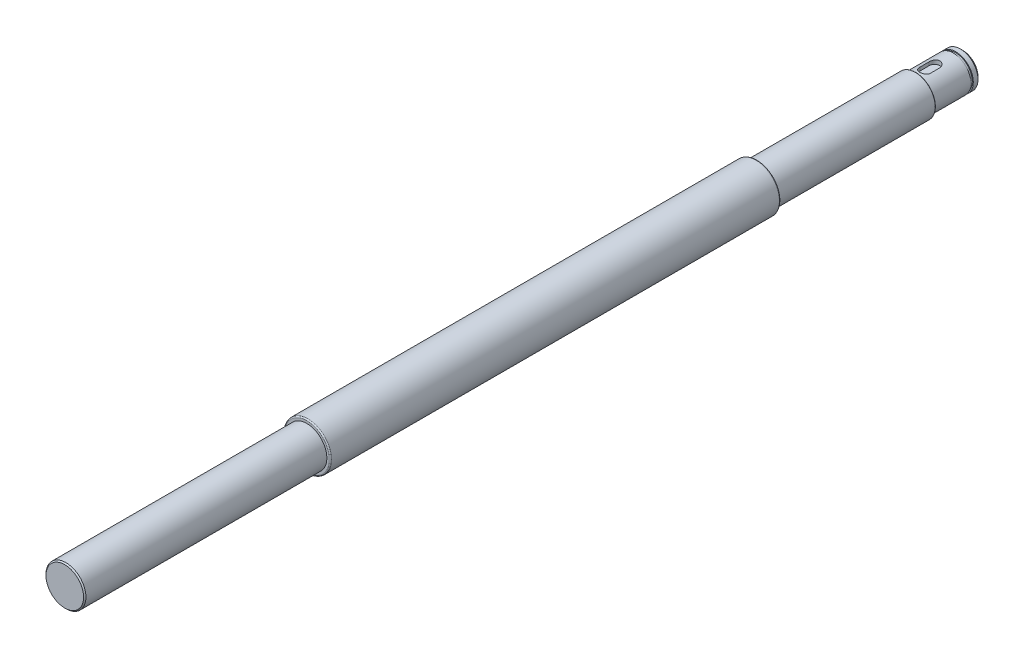
from build123d import *

# Parameters (mm, degrees)
SKETCH1_R               = 10
BOSS_EXTRUDE1_DEPTH     = 191.5
SKETCH2_R               = 8.5
BOSS_EXTRUDE2_DEPTH     = 103
SKETCH4_R               = 8.5
BOSS_EXTRUDE3_DEPTH     = 67.5
FILLET1_R               = 0.5
FILLET2_R               = 0.5
SKETCH6_R               = 7.5
BOSS_EXTRUDE4_DEPTH     = 20
CUT_EXTRUDE1_DEPTH      = 1.8
SKETCH8_R               = 17.075
SKETCH8_R_2             = 7.075
CUT_EXTRUDE_THIN1_DEPTH = 1
FILLET3_R               = 0.25
CHAMFER1_SIZE           = 1
CHAMFER2_SIZE           = 0.5


with BuildPart() as part:
    # Sketch1 → Boss-Extrude1 (new body)
    with BuildSketch(Plane.XY):
        Circle(SKETCH1_R)
    extrude(amount=BOSS_EXTRUDE1_DEPTH)

    # Sketch2 → Boss-Extrude2 (add)
    with BuildSketch(Plane.XY.offset(191.5)):
        Circle(SKETCH2_R)
    extrude(amount=BOSS_EXTRUDE2_DEPTH)

    # Sketch4 → Boss-Extrude3 (add)
    with BuildSketch(Plane(origin=(0, 0, 0), x_dir=(-1, 0, 0), z_dir=(0, 0, -1))):
        Circle(SKETCH4_R)
    extrude(amount=BOSS_EXTRUDE3_DEPTH)

    # Fillet1
    fillet1_edges = [part.edges().sort_by_distance(p)[0] for p in [
        (-10, 0, 191.5),
    ]]
    fillet(fillet1_edges, radius=FILLET1_R)

    # Fillet2
    fillet2_edges = [part.edges().sort_by_distance(p)[0] for p in [
        (-10, 0, 0),
    ]]
    fillet(fillet2_edges, radius=FILLET2_R)

    # Sketch6 → Boss-Extrude4 (add)
    with BuildSketch(Plane(origin=(0, 0, -67.5), x_dir=(-1, 0, 0), z_dir=(0, 0, -1))):
        Circle(SKETCH6_R)
    extrude(amount=BOSS_EXTRUDE4_DEPTH)

    # Sketch7 → Cut-Extrude1 (cut)
    with BuildSketch(Plane(origin=(0, 7.5, 0), x_dir=(-1, 0, 0), z_dir=(0, 1, 0))):
        with BuildLine():
            Line((2.25, -75.5), (2.25, -71.5))
            ThreePointArc((2.25, -71.5), (0, -69.25), (-2.25, -71.5))
            Line((-2.25, -71.5), (-2.25, -75.5))
            ThreePointArc((-2.25, -75.5), (0, -77.75), (2.25, -75.5))
        make_face()
    extrude(amount=-CUT_EXTRUDE1_DEPTH, mode=Mode.SUBTRACT)

    # Sketch8 → Cut-Extrude-Thin1 (cut)
    with BuildSketch(Plane.XY.offset(-83.5)):
        Circle(SKETCH8_R)
        Circle(SKETCH8_R_2, mode=Mode.SUBTRACT)
    extrude(amount=-CUT_EXTRUDE_THIN1_DEPTH, mode=Mode.SUBTRACT)

    # Fillet3
    fillet3_edges = [part.edges().sort_by_distance(p)[0] for p in [
        (8.5, 0, -67.5),
    ]]
    fillet(fillet3_edges, radius=FILLET3_R)

    # Chamfer1
    chamfer1_edges = [part.edges().sort_by_distance(p)[0] for p in [
        (7.5, 0, -87.5),
    ]]
    chamfer(chamfer1_edges, length=CHAMFER1_SIZE)

    # Chamfer2
    chamfer2_edges = [part.edges().sort_by_distance(p)[0] for p in [
        (-8.5, 0, 294.5),
    ]]
    chamfer(chamfer2_edges, length=CHAMFER2_SIZE)


solid = part.part
